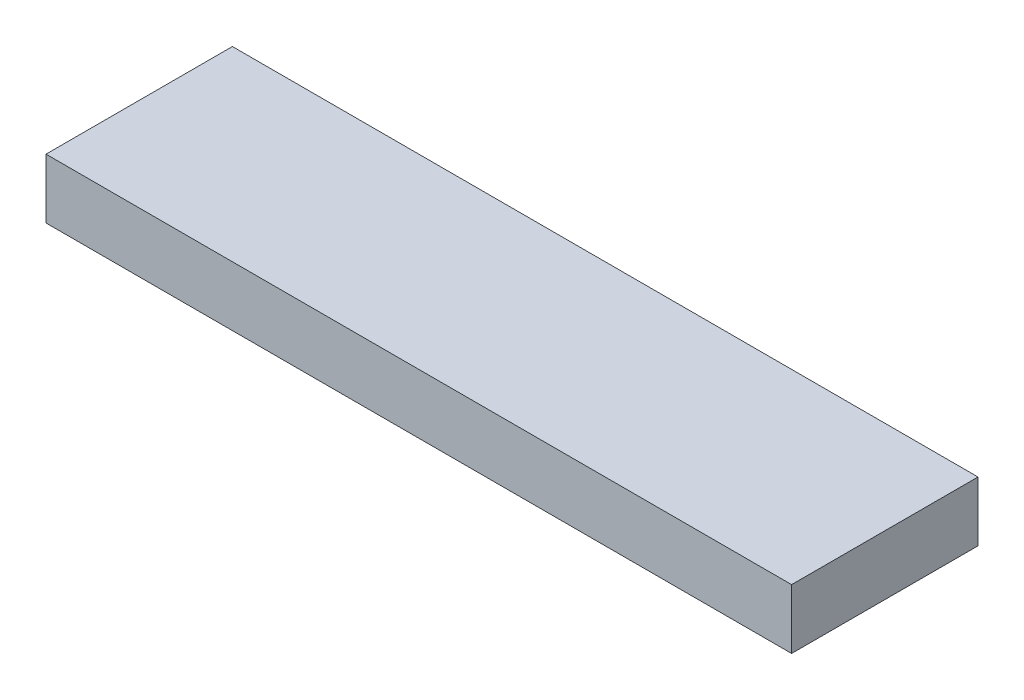
from build123d import *

# Parameters (mm, degrees)
ESQUISSE1_W      = 400
ESQUISSE1_H      = 100
EXTRUSION1_DEPTH = 32


with BuildPart() as part:
    # Esquisse1 → Extrusion1 (new body)
    with BuildSketch(Plane(origin=(0, 0, 0), x_dir=(1, 0, 0), z_dir=(0, 1, 0))):
        with Locations((200, 50)):
            Rectangle(ESQUISSE1_W, ESQUISSE1_H)
    extrude(amount=EXTRUSION1_DEPTH)


solid = part.part
